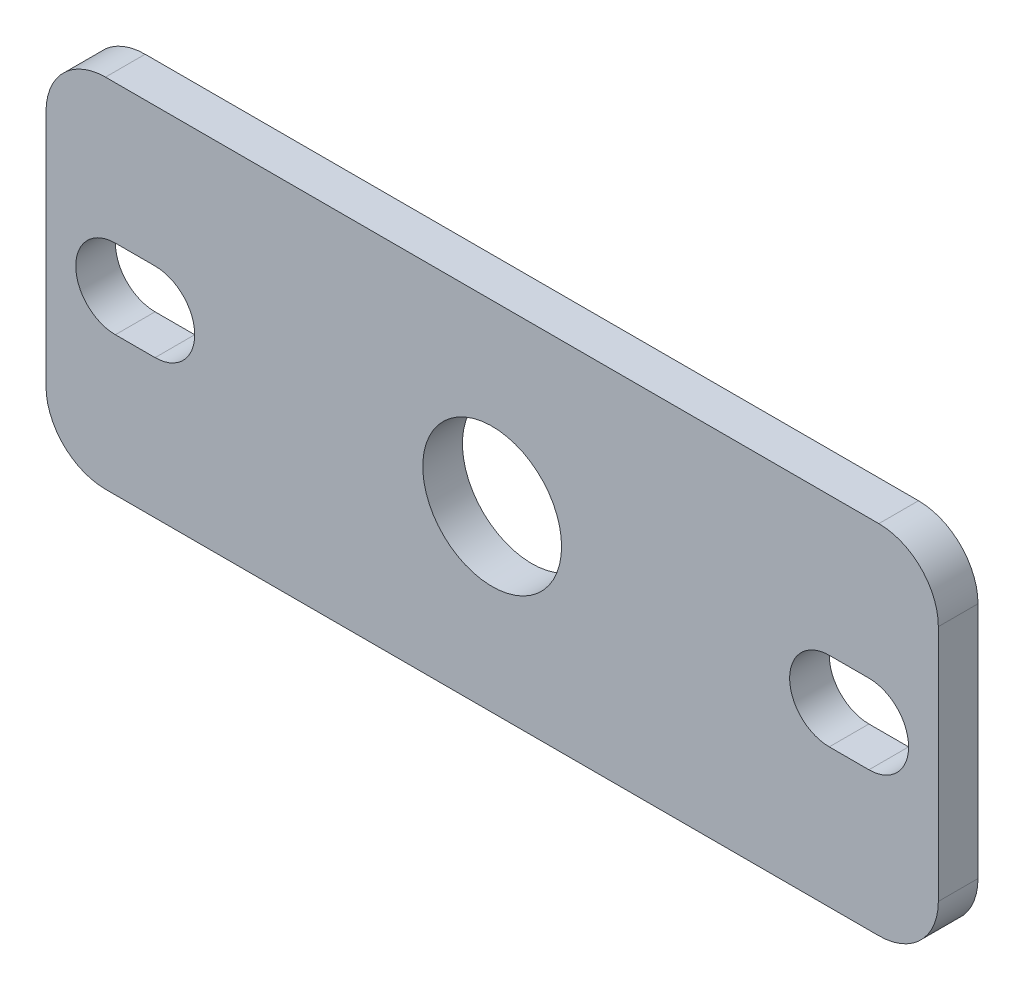
from build123d import *

# Parameters (mm, degrees)
ESQUISSE1_W             = 45
ESQUISSE1_H             = 18
EXTRUSION1_DEPTH        = 2
CONG_1_R                = 3
ENL_V_MAT_EXTRU_1_REACH = 4
ESQUISSE2_R             = 3.5


with BuildPart() as part:
    # Esquisse1 → Extrusion1 (new body)
    with BuildSketch(Plane.XY):
        Rectangle(ESQUISSE1_W, ESQUISSE1_H)
    extrude(amount=EXTRUSION1_DEPTH)

    # Congé1
    cong_1_edges = [part.edges().sort_by_distance(p)[0] for p in [
        (-22.5, 9, 1),
        (22.5, 9, 1),
        (22.5, -9, 1),
        (-22.5, -9, 1),
    ]]
    fillet(cong_1_edges, radius=CONG_1_R)

    # Esquisse2 → Enlèv. mat.-Extru.1 (cut, up to next)
    with BuildSketch(Plane.XY.offset(2), mode=Mode.PRIVATE) as enl_v_mat_extru_1_sk1:
        Circle(ESQUISSE2_R)
    enl_v_mat_extru_1_tool1 = extrude(enl_v_mat_extru_1_sk1.sketch, amount=-ENL_V_MAT_EXTRU_1_REACH, mode=Mode.PRIVATE) & part.part
    add(enl_v_mat_extru_1_tool1.solids().sort_by_distance((0, 0, 2))[0], mode=Mode.SUBTRACT)
    # Esquisse2 → Enlèv. mat.-Extru.1 (cut, up to next)
    with BuildSketch(Plane.XY.offset(2), mode=Mode.PRIVATE) as enl_v_mat_extru_1_sk2:
        with BuildLine():
            Line((17, 2), (19, 2))
            ThreePointArc((19, 2), (21, 0), (19, -2))
            Line((19, -2), (17, -2))
            ThreePointArc((17, -2), (15, 0), (17, 2))
        make_face()
    enl_v_mat_extru_1_tool2 = extrude(enl_v_mat_extru_1_sk2.sketch, amount=-ENL_V_MAT_EXTRU_1_REACH, mode=Mode.PRIVATE) & part.part
    add(enl_v_mat_extru_1_tool2.solids().sort_by_distance((18, 0, 2))[0], mode=Mode.SUBTRACT)
    # Esquisse2 → Enlèv. mat.-Extru.1 (cut, up to next)
    with BuildSketch(Plane.XY.offset(2), mode=Mode.PRIVATE) as enl_v_mat_extru_1_sk3:
        with BuildLine():
            Line((-19, -2), (-17, -2))
            ThreePointArc((-17, -2), (-15, 0), (-17, 2))
            Line((-17, 2), (-19, 2))
            ThreePointArc((-19, 2), (-21, 0), (-19, -2))
        make_face()
    enl_v_mat_extru_1_tool3 = extrude(enl_v_mat_extru_1_sk3.sketch, amount=-ENL_V_MAT_EXTRU_1_REACH, mode=Mode.PRIVATE) & part.part
    add(enl_v_mat_extru_1_tool3.solids().sort_by_distance((-18, 0, 2))[0], mode=Mode.SUBTRACT)


solid = part.part
